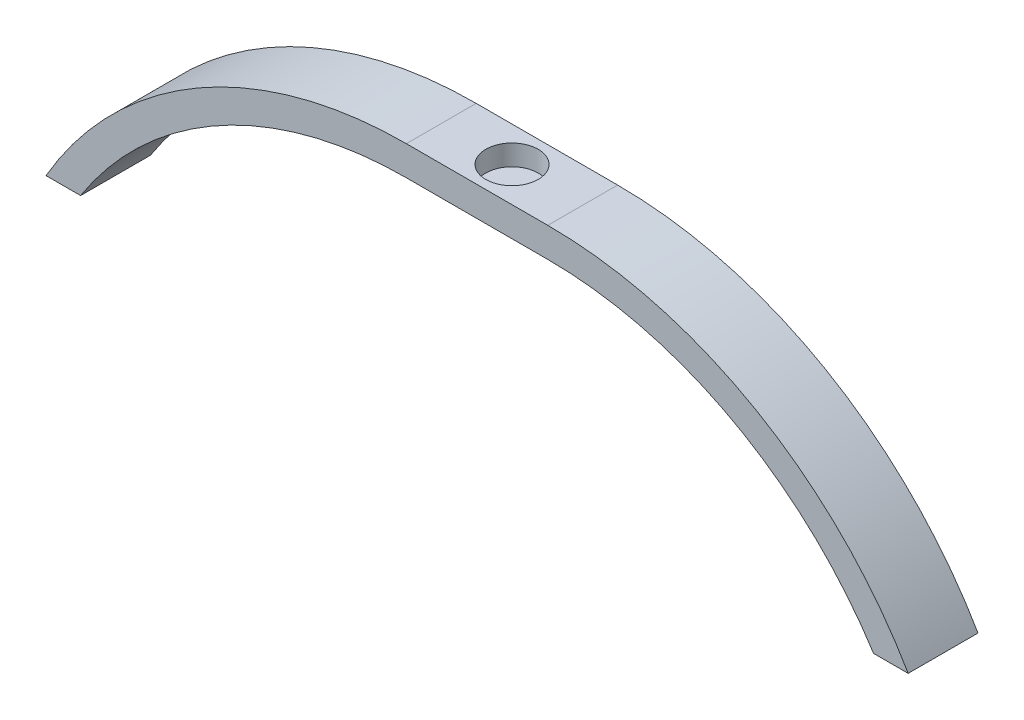
from build123d import *

# Parameters (mm, degrees)
BOSS_EXTRUDE1_DEPTH = 10.16
SKETCH2_R           = 3.81
CUT_EXTRUDE1_DEPTH  = 3


with BuildPart() as part:
    # Sketch1 → Boss-Extrude1 (new body)
    with BuildSketch(Plane.XY):
        with BuildLine():
            Line((-10.29, 60.569999994), (10.29, 60.569999994))
            ThreePointArc((10.29, 60.569999994), (40.552972239, 52.46835927), (62.72, 30.329999994))
            Line((62.72, 30.329999994), (57.687092381, 30.329999994))
            ThreePointArc((57.687092381, 30.329999994), (37.305705234, 49.361020835), (10.290030094, 56.269999994))
            Line((10.290030094, 56.269999994), (-10.290030094, 56.269999994))
            ThreePointArc((-10.290030094, 56.269999994), (-37.305705234, 49.361020835), (-57.687092381, 30.329999994))
            Line((-57.687092381, 30.329999994), (-62.72, 30.329999994))
            ThreePointArc((-62.72, 30.329999994), (-40.552972239, 52.46835927), (-10.29, 60.569999994))
        make_face()
    extrude(amount=BOSS_EXTRUDE1_DEPTH)

    # Sketch2 → Cut-Extrude1 (cut)
    with BuildSketch(Plane(origin=(0, 60.569999994, 0), x_dir=(1, 0, 0), z_dir=(0, 1, 0))):
        with Locations((0, -5.08)):
            Circle(SKETCH2_R)
    extrude(amount=-CUT_EXTRUDE1_DEPTH, mode=Mode.SUBTRACT)


solid = part.part
